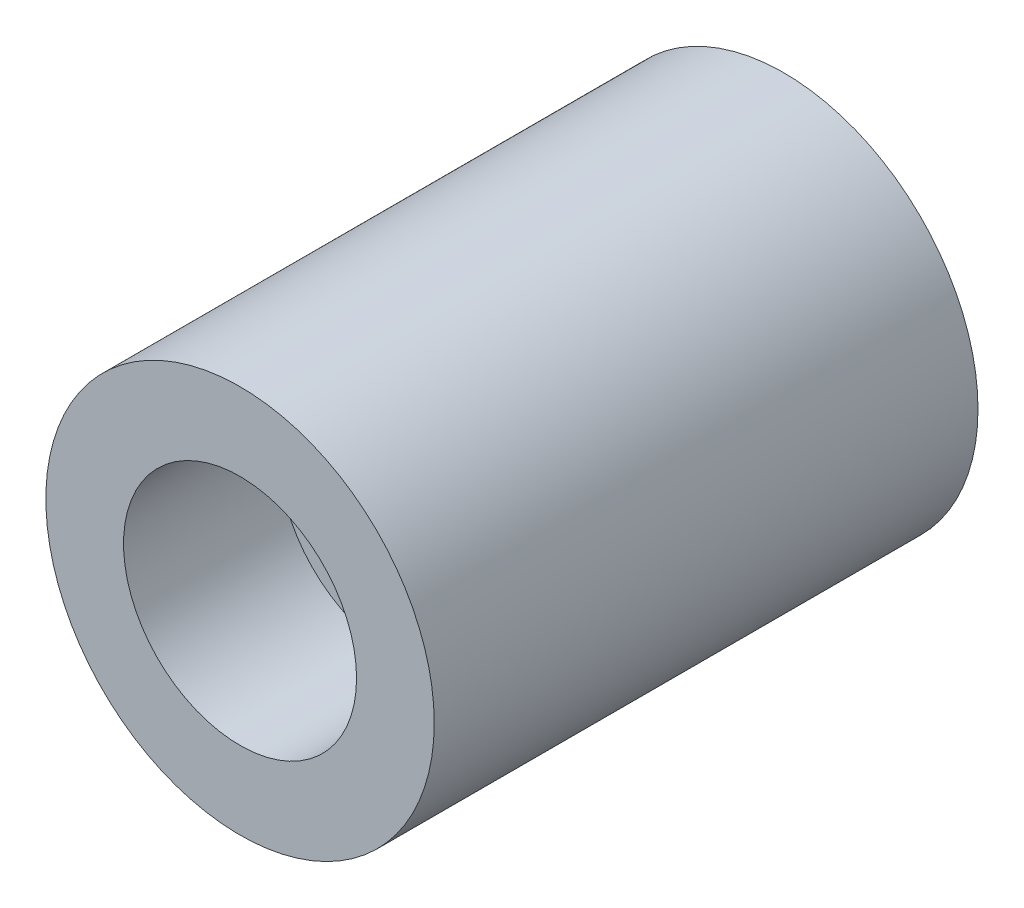
from build123d import *

# Parameters (mm, degrees)
SKETCH2_R           = 50
BOSS_EXTRUDE1_DEPTH = 140
SKETCH3_R           = 30
CUT_EXTRUDE1_DEPTH  = 40
SKETCH4_R           = 10
CUT_EXTRUDE2_DEPTH  = 120


with BuildPart() as part:
    # Sketch2 → Boss-Extrude1 (new body)
    with BuildSketch(Plane.XY):
        Circle(SKETCH2_R)
    extrude(amount=BOSS_EXTRUDE1_DEPTH)

    # Sketch3 → Cut-Extrude1 (cut)
    with BuildSketch(Plane.XY.offset(140)):
        Circle(SKETCH3_R)
    extrude(amount=-CUT_EXTRUDE1_DEPTH, mode=Mode.SUBTRACT)

    # Sketch4 → Cut-Extrude2 (cut)
    with BuildSketch(Plane.XY.offset(140)):
        Circle(SKETCH4_R)
    extrude(amount=-CUT_EXTRUDE2_DEPTH, mode=Mode.SUBTRACT)


solid = part.part
